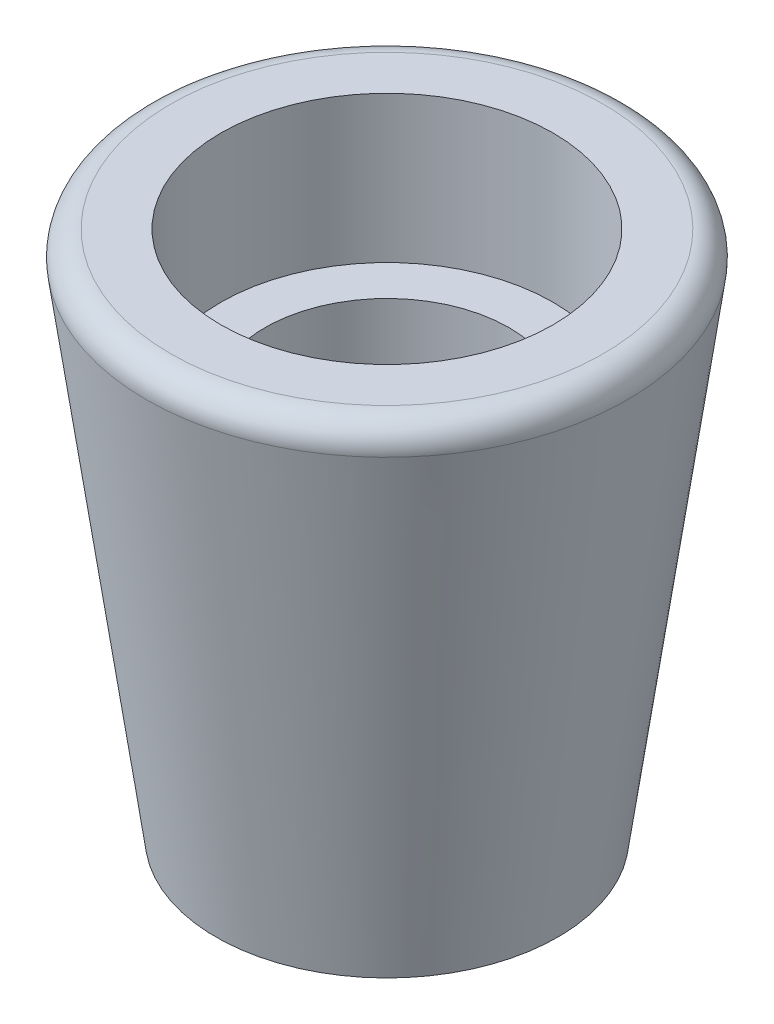
from build123d import *

# Parameters (mm, degrees)
FILLET1_R = 0.5


with BuildPart() as part:
    # Sketch1 → Revolve1 (revolve)
    with BuildSketch(Plane.XY):
        Polygon((2.5, 0), (3.5, 0), (5, 10.8), (3.4, 10.8), (3.4, 7.8), (2.5, 7.8), align=None)
    revolve(axis=Axis((0, 0, 0), (0, 1, 0)))

    # Fillet1
    fillet1_edges = [part.edges().sort_by_distance(p)[0] for p in [
        (-5, 10.8, 0),
    ]]
    fillet(fillet1_edges, radius=FILLET1_R)


solid = part.part
